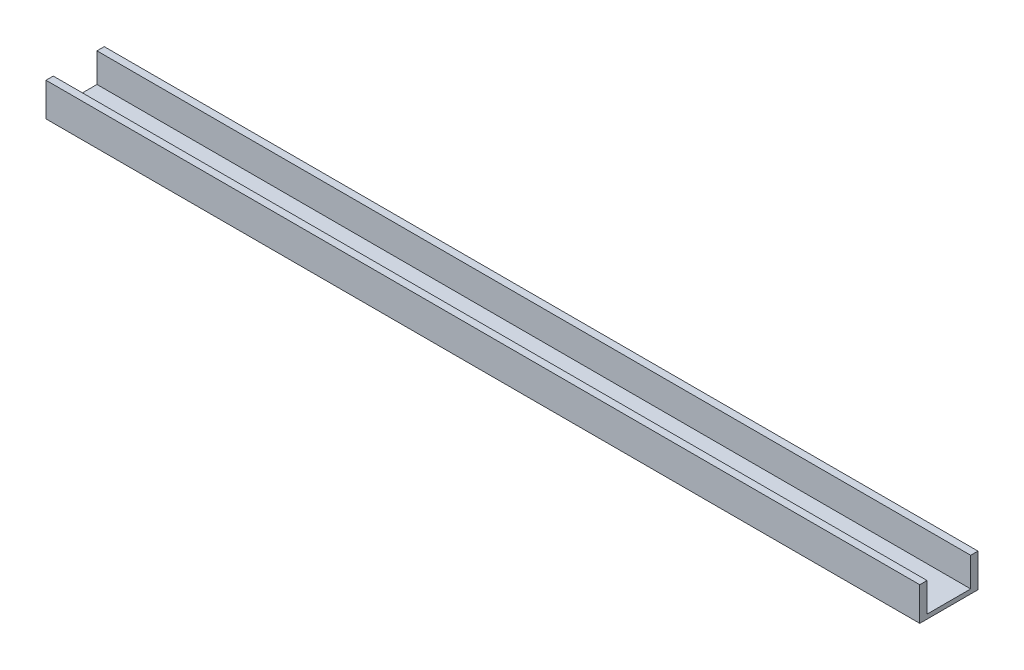
from build123d import *

# Parameters (mm, degrees)
SKETCH1_W           = 600
SKETCH1_H           = 40
BOSS_EXTRUDE1_DEPTH = 3
SKETCH2_W           = 600
SKETCH2_H           = 5
BOSS_EXTRUDE2_DEPTH = 20


with BuildPart() as part:
    # Sketch1 → Boss-Extrude1 (new body)
    with BuildSketch(Plane(origin=(0, 0, 0), x_dir=(1, 0, 0), z_dir=(0, 1, 0))):
        Rectangle(SKETCH1_W, SKETCH1_H)
    extrude(amount=BOSS_EXTRUDE1_DEPTH)

    # Sketch2 → Boss-Extrude2 (add)
    with BuildSketch(Plane(origin=(0, 3, 0), x_dir=(1, 0, 0), z_dir=(0, 1, 0))):
        with Locations((0, 17.5)):
            Rectangle(SKETCH2_W, SKETCH2_H)
        with Locations((0, -17.5)):
            Rectangle(SKETCH2_W, SKETCH2_H)
    extrude(amount=BOSS_EXTRUDE2_DEPTH)


solid = part.part
